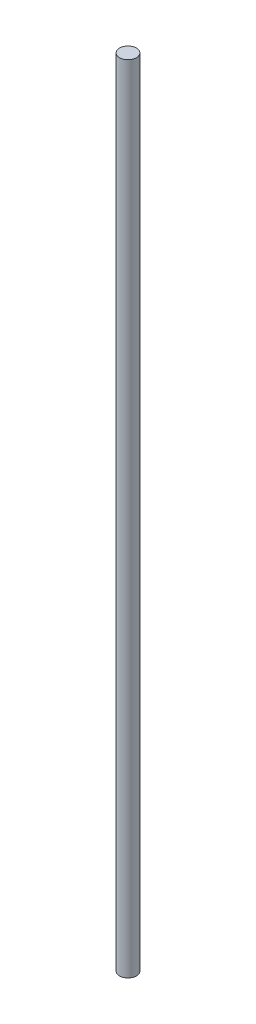
from build123d import *

# Parameters (mm, degrees)
ESQUISSE1_R      = 3
EXTRUSION1_DEPTH = 284


with BuildPart() as part:
    # Esquisse1 → Extrusion1 (new body)
    with BuildSketch(Plane(origin=(0, 0, 0), x_dir=(1, 0, 0), z_dir=(0, 1, 0))):
        with Locations(Location((0, 0, 0), (0, 0, 270))):  # turned: the seam where the file's is
            Circle(ESQUISSE1_R)
    extrude(amount=EXTRUSION1_DEPTH)


solid = part.part
